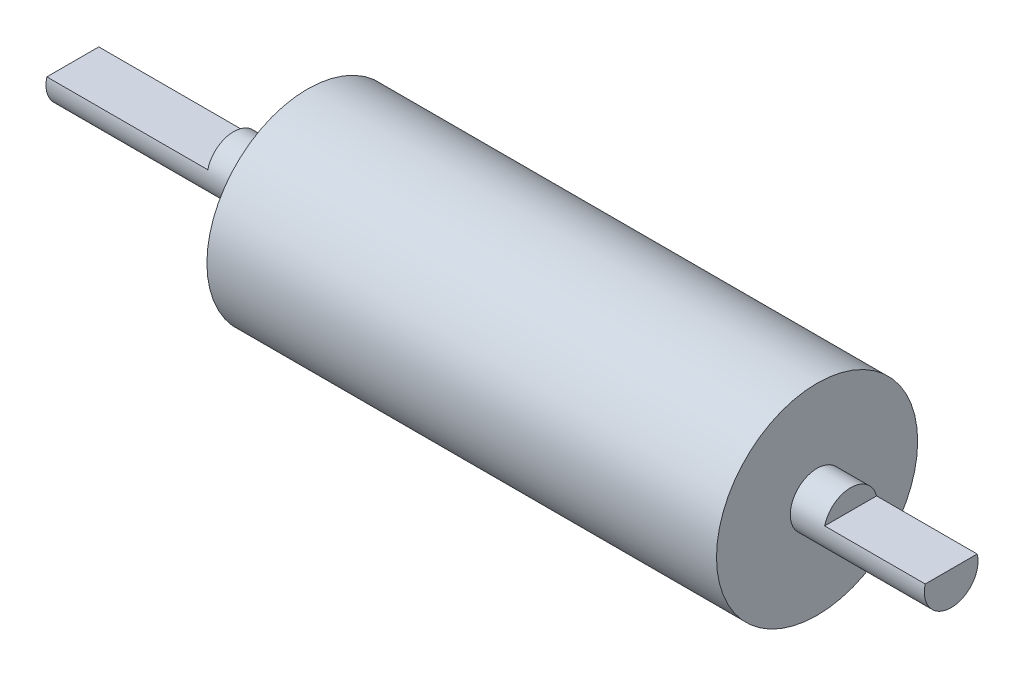
from build123d import *

# Parameters (mm, degrees)
ESBO_O8_R                = 4
RESSALTO_EXTRUS_O4_DEPTH = 35
ESBO_O9_R                = 15
RESSALTO_EXTRUS_O5_DEPTH = 76
ESBO_O10_R               = 4
RESSALTO_EXTRUS_O6_DEPTH = 20
ESBO_O11_W               = 11.087956956
ESBO_O11_H               = 3
CORTE_EXTRUS_O1_DEPTH    = 24
ESBO_O12_W               = 18.763421195
ESBO_O12_H               = 3
CORTE_EXTRUS_O2_DEPTH    = 15


with BuildPart() as part:
    # Esboço8 → Ressalto-extrusão4 (new body)
    with BuildSketch(Plane(origin=(0, 0, 0), x_dir=(0, 0, -1), z_dir=(1, 0, 0))):
        Circle(ESBO_O8_R)
    extrude(amount=RESSALTO_EXTRUS_O4_DEPTH)

    # Esboço9 → Ressalto-extrusão5 (add)
    with BuildSketch(Plane(origin=(35, 0, 0), x_dir=(0, 0, -1), z_dir=(1, 0, 0))):
        Circle(ESBO_O9_R)
    extrude(amount=RESSALTO_EXTRUS_O5_DEPTH)

    # Esboço10 → Ressalto-extrusão6 (add)
    with BuildSketch(Plane(origin=(111, 0, 0), x_dir=(0, 0, -1), z_dir=(1, 0, 0))):
        Circle(ESBO_O10_R)
    extrude(amount=RESSALTO_EXTRUS_O6_DEPTH)

    # Esboço11 → Corte-extrusão1 (cut)
    with BuildSketch(Plane.ZY):
        with Locations((0, 2.5)):
            Rectangle(ESBO_O11_W, ESBO_O11_H)
    extrude(amount=-CORTE_EXTRUS_O1_DEPTH, mode=Mode.SUBTRACT)

    # Esboço12 → Corte-extrusão2 (cut)
    with BuildSketch(Plane(origin=(131, 0, 0), x_dir=(0, 0, -1), z_dir=(1, 0, 0))):
        with Locations((-0.1910881, 2.5)):
            Rectangle(ESBO_O12_W, ESBO_O12_H)
    extrude(amount=-CORTE_EXTRUS_O2_DEPTH, mode=Mode.SUBTRACT)


solid = part.part
